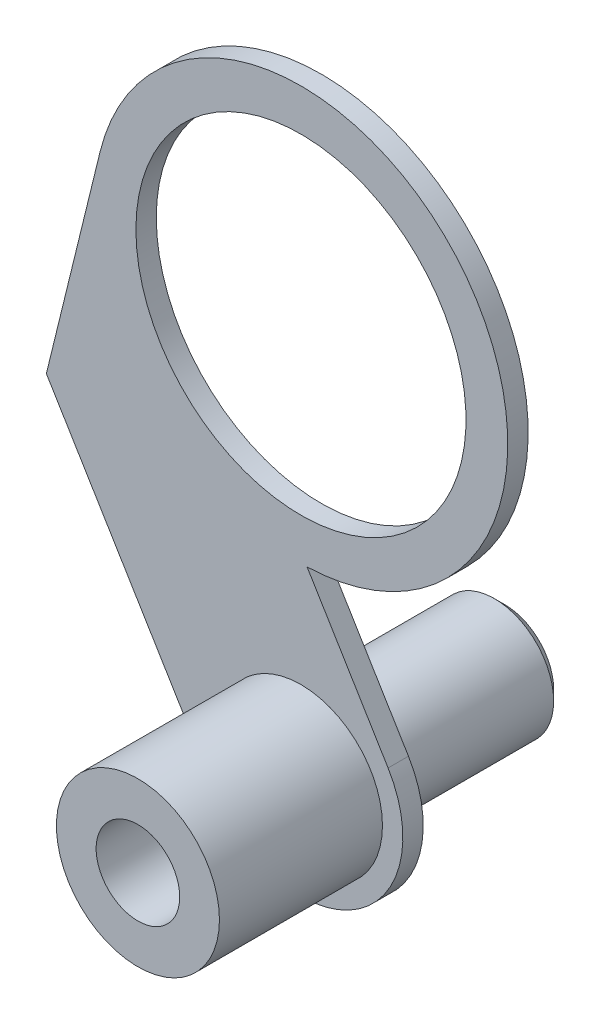
from build123d import *

# Parameters (mm, degrees)
SKETCH2_R           = 2.95
SKETCH2_R_2         = 8.099999999
BOSS_EXTRUDE1_DEPTH = 1


with BuildPart() as part:
    # Sketch1 → Revolve1 (revolve)
    with BuildSketch(Plane(origin=(0, 0, 0), x_dir=(0, 0, -1), z_dir=(1, 0, 0))):
        Polygon((18, 2.05), (18, 2.4), (17.5, 2.9), (8, 2.9), (8, 4), (0, 4), (0, 2.05), align=None)
    revolve(axis=Axis((0, 0, 0), (0, 0, -1)))

    # Sketch2 → Boss-Extrude1 (add)
    with BuildSketch(Plane(origin=(0, 0, -8), x_dir=(-1, 0, 0), z_dir=(0, 0, -1))):
        with BuildLine():
            Line((9.857790067, 21.711729889), (12.493283293, 10.967026744))
            Line((12.493283293, 10.967026744), (4.275989158, -2.59150858))
            ThreePointArc((4.275989158, -2.59150858), (-2.59150858, -4.275989158), (-4.275989158, 2.59150858))
            Line((-4.275989158, 2.59150858), (-0.302187827, 9.148280777))
            ThreePointArc((-0.302187827, 9.148280777), (-7.892239666, 25.676183207), (9.857790067, 21.711729889))
        make_face()
        Circle(SKETCH2_R, mode=Mode.SUBTRACT)
        with Locations((0, 19.293781382)):
            Circle(SKETCH2_R_2, mode=Mode.SUBTRACT)
    extrude(amount=BOSS_EXTRUDE1_DEPTH)


solid = part.part
